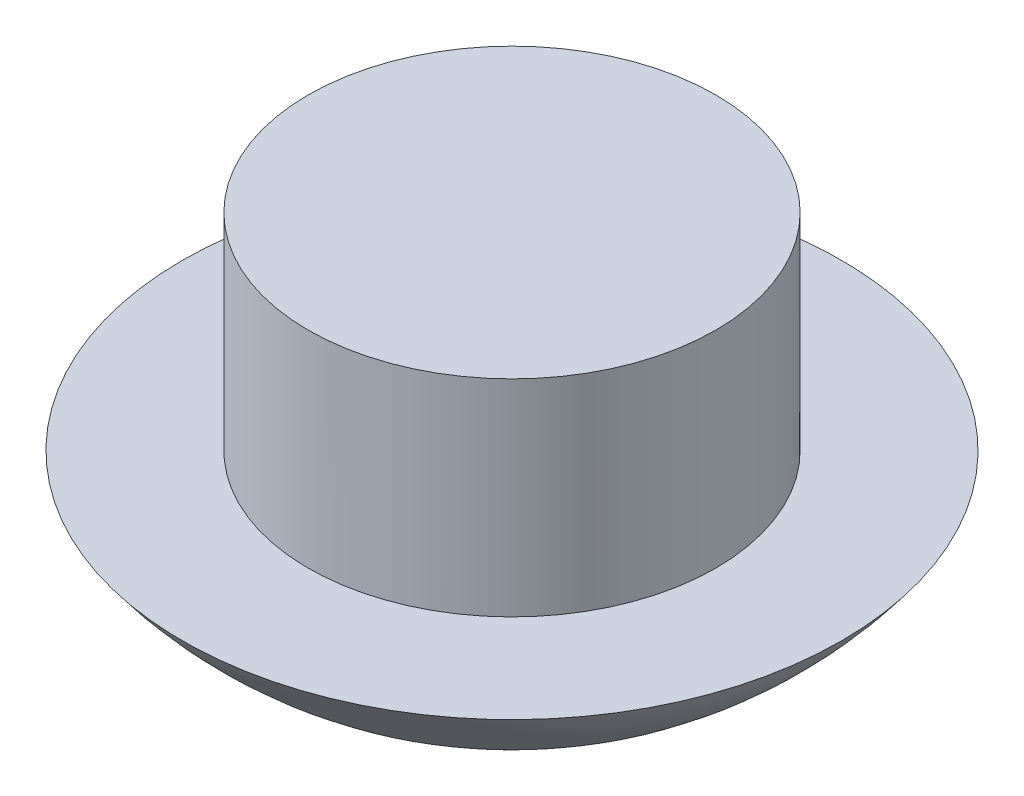
from build123d import *

# Parameters (mm, degrees)
SKETCH2_R          = 10.795
CUT_EXTRUDE1_DEPTH = 1.778


with BuildPart() as part:
    # Sketch1 one side → Revolve5 (revolve)
    with BuildSketch(Plane.XY):
        with BuildLine():
            Line((0, 0), (-10.795, 0))
            Line((-10.795, 0), (-10.795, -12.7))
            Line((-10.795, -12.7), (-17.459613398, -12.7))
            ThreePointArc((-17.459613398, -12.7), (-9.796302874, -19.239556908), (0, -21.59))
            Line((0, -21.59), (0, 0))
        make_face()
    revolve(axis=Axis((0, -21.59, 0), (0, 1, 0)))

    # Sketch2 → Cut-Extrude1 (cut)
    with BuildSketch(Plane(origin=(0, 0, 0), x_dir=(1, 0, 0), z_dir=(0, 1, 0))):
        Circle(SKETCH2_R)
    extrude(amount=-CUT_EXTRUDE1_DEPTH, mode=Mode.SUBTRACT)


solid = part.part
